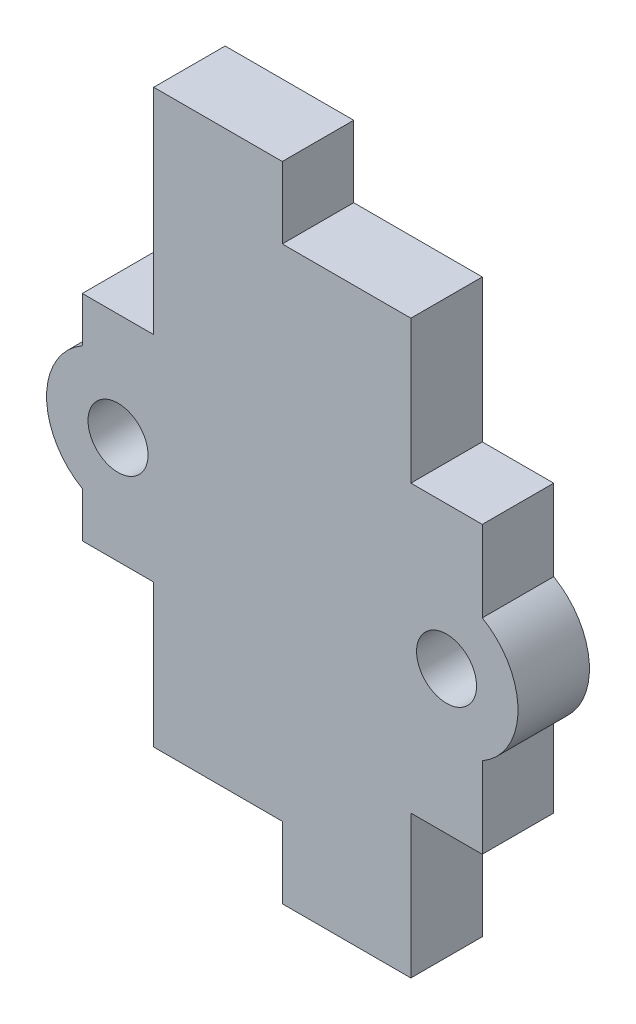
from build123d import *

# Parameters (mm, degrees)
SKETCH1_W           = 18
SKETCH1_H           = 35
BOSS_EXTRUDE1_DEPTH = 5
SKETCH2_W           = 5
SKETCH2_H           = 20
BOSS_EXTRUDE2_DEPTH = 5
SKETCH3_W           = 9
SKETCH3_H           = 5
BOSS_EXTRUDE3_DEPTH = 5
SKETCH4_W           = 5
SKETCH4_H           = 15
BOSS_EXTRUDE4_DEPTH = 5
SKETCH5_W           = 9
SKETCH5_H           = 5
BOSS_EXTRUDE5_DEPTH = 5
SKETCH6_R           = 2.1
CUT_EXTRUDE1_DEPTH  = 5
BOSS_EXTRUDE6_DEPTH = 5
SKETCH8_R           = 2.1
CUT_EXTRUDE2_DEPTH  = 5
BOSS_EXTRUDE7_DEPTH = 5


with BuildPart() as part:
    # Sketch1 → Boss-Extrude1 (new body)
    with BuildSketch(Plane.XY):
        with Locations((-9, 17.5)):
            Rectangle(SKETCH1_W, SKETCH1_H)
    extrude(amount=BOSS_EXTRUDE1_DEPTH)

    # Sketch2 → Boss-Extrude2 (add)
    with BuildSketch(Plane(origin=(0, 0, 0), x_dir=(0, 0, -1), z_dir=(1, 0, 0))):
        with Locations((-2.5, 15)):
            Rectangle(SKETCH2_W, SKETCH2_H)
    extrude(amount=BOSS_EXTRUDE2_DEPTH)

    # Sketch3 → Boss-Extrude3 (add)
    with BuildSketch(Plane.XZ):
        with Locations((-4.5, 2.5)):
            Rectangle(SKETCH3_W, SKETCH3_H)
    extrude(amount=BOSS_EXTRUDE3_DEPTH)

    # Sketch4 → Boss-Extrude4 (add)
    with BuildSketch(Plane.XY.offset(5)):
        with Locations((-20.5, 17.5)):
            Rectangle(SKETCH4_W, SKETCH4_H)
    extrude(amount=-BOSS_EXTRUDE4_DEPTH)

    # Sketch5 → Boss-Extrude5 (add)
    with BuildSketch(Plane(origin=(0, 35, 0), x_dir=(1, 0, 0), z_dir=(0, 1, 0))):
        with Locations((-13.5, -2.5)):
            Rectangle(SKETCH5_W, SKETCH5_H)
    extrude(amount=BOSS_EXTRUDE5_DEPTH)

    # Sketch6 → Cut-Extrude1 (cut)
    with BuildSketch(Plane(origin=(0, 0, 0), x_dir=(-1, 0, 0), z_dir=(0, 0, -1))):
        with Locations((-2.5, 15)):
            Circle(SKETCH6_R)
    extrude(amount=-CUT_EXTRUDE1_DEPTH, mode=Mode.SUBTRACT)

    # Sketch7 → Boss-Extrude6 (add)
    with BuildSketch(Plane(origin=(0, 0, 0), x_dir=(-1, 0, 0), z_dir=(0, 0, -1))):
        with BuildLine():
            Line((-5, 10.669872981), (-5, 19.330127019))
            ThreePointArc((-5, 19.330127019), (-7.5, 15), (-5, 10.669872981))
        make_face()
    extrude(amount=-BOSS_EXTRUDE6_DEPTH)

    # Sketch8 → Cut-Extrude2 (cut)
    with BuildSketch(Plane.XY.offset(5)):
        with Locations((-20.5, 17.5)):
            Circle(SKETCH8_R)
    extrude(amount=-CUT_EXTRUDE2_DEPTH, mode=Mode.SUBTRACT)

    # Sketch9 → Boss-Extrude7 (add)
    with BuildSketch(Plane.XY.offset(5)):
        with BuildLine():
            Line((-23, 13.169872981), (-23, 21.830127019))
            ThreePointArc((-23, 21.830127019), (-25.5, 17.5), (-23, 13.169872981))
        make_face()
    extrude(amount=-BOSS_EXTRUDE7_DEPTH)


solid = part.part
